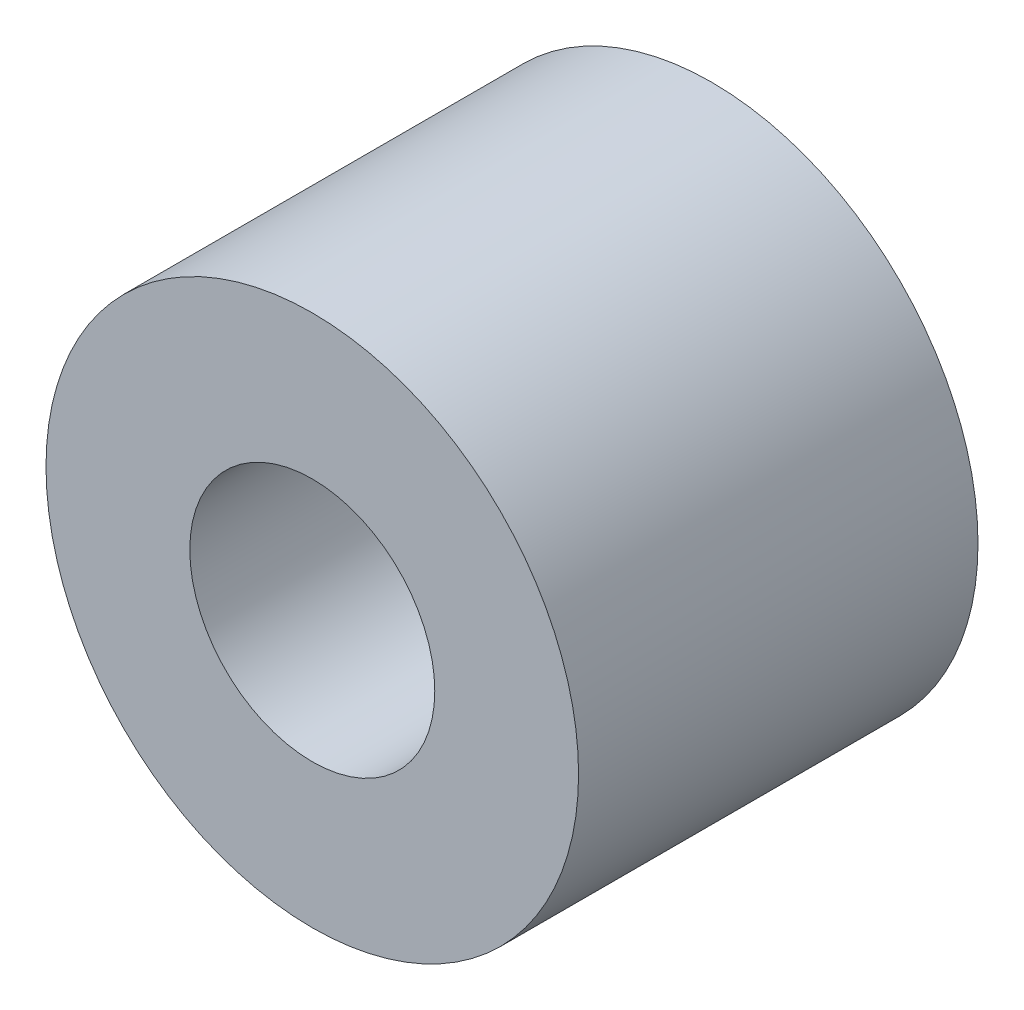
from build123d import *

# Parameters (mm, degrees)
SKETCH1_R      = 3.175
SKETCH1_R_2    = 1.4605
EXTRUDE1_DEPTH = 2.38125


with BuildPart() as part:
    # Sketch1 → Extrude1 (new body, symmetric)
    with BuildSketch(Plane.XY):
        Circle(SKETCH1_R)
        Circle(SKETCH1_R_2, mode=Mode.SUBTRACT)
    extrude(amount=EXTRUDE1_DEPTH, both=True)


solid = part.part
